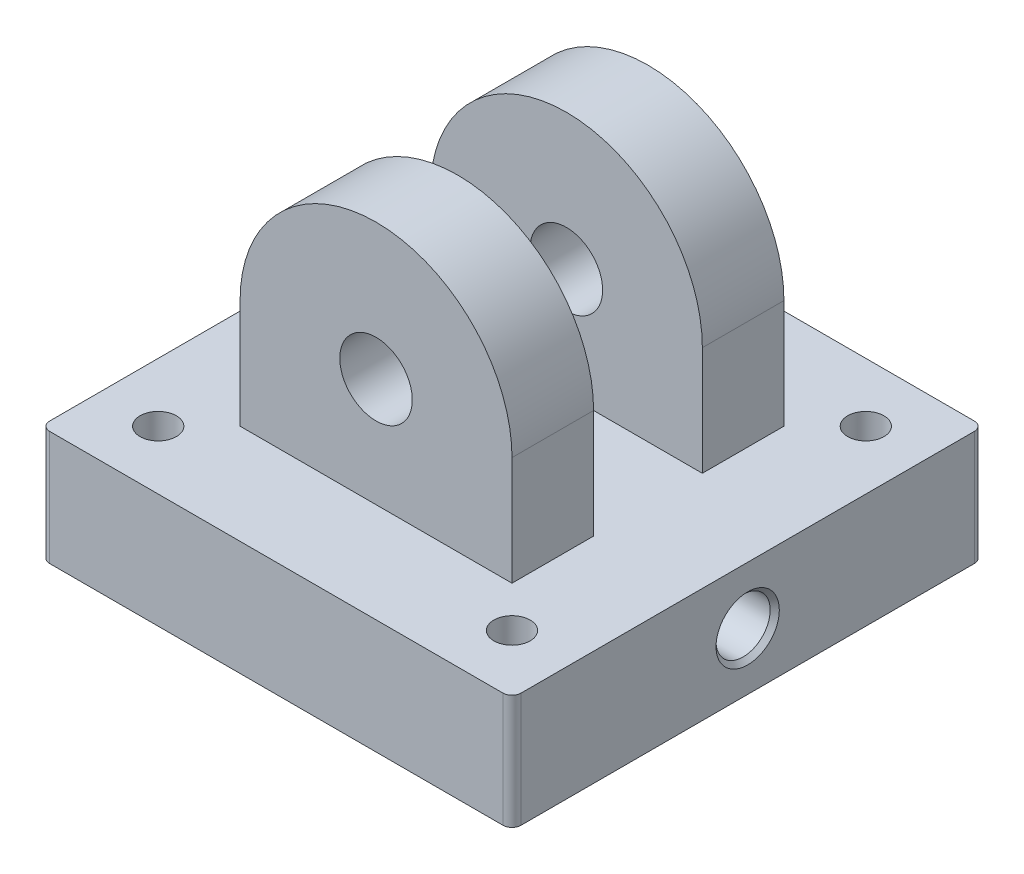
from build123d import *

# Parameters (mm, degrees)
SKETCH1_W                              = 165.1
SKETCH1_H                              = 165.1
BOSS_EXTRUDE1_DEPTH                    = 38.1
BOSS_EXTRUDE1_DEPTH_BACK               = 2
SKETCH2_W                              = 95.25
SKETCH2_H                              = 95.25
BOSS_EXTRUDE2_DEPTH                    = 38.1
BOSS_EXTRUDE3_START                    = -95.25
BOSS_EXTRUDE3_DEPTH                    = 95.25
SKETCH7_R                              = 12.7
CUT_EXTRUDE1_DEPTH                     = 131.175
SKETCH8_W                              = 38.1
SKETCH8_H                              = 1000
CUT_EXTRUDE2_DEPTH                     = 131.175
FILLET1_R                              = 3.175
SKETCH9_R                              = 26
CUT_EXTRUDE3_DEPTH                     = 36.83
SKETCH10_R                             = 76.2
SKETCH10_R_2                           = 69.85
CUT_EXTRUDE4_DEPTH                     = 8
F_1_2_14_NPSM_TAPPED_HOLE2_D           = 18.9738
F_1_2_14_NPSM_TAPPED_HOLE2_DEPTH       = 63.5
F_1_2_14_NPSM_TAPPED_HOLE2_CSINK_D     = 22.1742
F_1_2_14_NPSM_TAPPED_HOLE2_CSINK_ANGLE = 90
F_1_2_14_NPSM_TAPPED_HOLE2_TIP         = 5.700304607
SKETCH16_R                             = 6.35
CUT_EXTRUDE5_DEPTH                     = 25
SKETCH17_R                             = 6.35
CUT_EXTRUDE6_DEPTH                     = 126.825


with BuildPart() as part:
    # Sketch1 → Boss-Extrude1 (new body, two sides)
    with BuildSketch(Plane(origin=(0, 0, 0), x_dir=(1, 0, 0), z_dir=(0, 1, 0))) as boss_extrude1_sk:
        Rectangle(SKETCH1_W, SKETCH1_H)
    extrude(amount=BOSS_EXTRUDE1_DEPTH)
    extrude(boss_extrude1_sk.sketch, amount=-BOSS_EXTRUDE1_DEPTH_BACK)

    # Sketch2 → Boss-Extrude2 (add)
    with BuildSketch(Plane(origin=(0, 38.1, 0), x_dir=(1, 0, 0), z_dir=(0, 1, 0))):
        Rectangle(SKETCH2_W, SKETCH2_H)
    extrude(amount=BOSS_EXTRUDE2_DEPTH)

    # Sketch3 → Boss-Extrude3 (add)
    with BuildSketch(Plane(origin=(0, 0, -47.625), x_dir=(-1, 0, 0), z_dir=(0, 0, -1)).offset(BOSS_EXTRUDE3_START)):
        with BuildLine():
            Line((47.625, 76.2), (-47.625, 76.2))
            ThreePointArc((-47.625, 76.2), (0, 123.825), (47.625, 76.2))
        make_face()
    extrude(amount=BOSS_EXTRUDE3_DEPTH)

    # Sketch7 → Cut-Extrude1 (cut, through all)
    with BuildSketch(Plane(origin=(0, 0, -47.625), x_dir=(-1, 0, 0), z_dir=(0, 0, -1))):
        with Locations((0, 76.2)):
            Circle(SKETCH7_R)
    extrude(amount=-CUT_EXTRUDE1_DEPTH, mode=Mode.SUBTRACT)

    # Sketch8 → Cut-Extrude2 (cut, through all)
    with BuildSketch(Plane(origin=(47.625, 0, 0), x_dir=(0, 0, -1), z_dir=(1, 0, 0))):
        with Locations((0, 538.1)):
            Rectangle(SKETCH8_W, SKETCH8_H)
    extrude(amount=-CUT_EXTRUDE2_DEPTH, mode=Mode.SUBTRACT)

    # Fillet1
    fillet1_edges = [part.edges().sort_by_distance(p)[0] for p in [
        (82.55, 18.05, 82.55),
        (-82.55, 18.05, 82.55),
        (-82.55, 18.05, -82.55),
        (82.55, 18.05, -82.55),
    ]]
    fillet(fillet1_edges, radius=FILLET1_R)

    # Sketch9 → Cut-Extrude3 (cut)
    with BuildSketch(Plane.XZ.offset(2)):
        Circle(SKETCH9_R)
    extrude(amount=-CUT_EXTRUDE3_DEPTH, mode=Mode.SUBTRACT)

    # Sketch10 → Cut-Extrude4 (cut)
    with BuildSketch(Plane.XZ.offset(2)):
        Circle(SKETCH10_R)
        Circle(SKETCH10_R_2, mode=Mode.SUBTRACT)
    extrude(amount=-CUT_EXTRUDE4_DEPTH, mode=Mode.SUBTRACT)

    # 1/2-14 NPSM Tapped Hole2
    with Locations(Plane(origin=(82.55, 0, 0), x_dir=(0, 0, -1), z_dir=(1, 0, 0))):
        with Locations((0, 18.05)):
            CounterSinkHole(F_1_2_14_NPSM_TAPPED_HOLE2_D / 2, F_1_2_14_NPSM_TAPPED_HOLE2_CSINK_D / 2, depth=F_1_2_14_NPSM_TAPPED_HOLE2_DEPTH, counter_sink_angle=F_1_2_14_NPSM_TAPPED_HOLE2_CSINK_ANGLE)
            with Locations((0, 0, -(F_1_2_14_NPSM_TAPPED_HOLE2_DEPTH + F_1_2_14_NPSM_TAPPED_HOLE2_TIP / 2))):  # 118° drill point
                Cone(0, F_1_2_14_NPSM_TAPPED_HOLE2_D / 2, F_1_2_14_NPSM_TAPPED_HOLE2_TIP, mode=Mode.SUBTRACT)

    # Sketch16 → Cut-Extrude5 (cut)
    with BuildSketch(Plane.XZ.offset(2)):
        with Locations((50.55, 0)):
            Circle(SKETCH16_R)
    extrude(amount=-CUT_EXTRUDE5_DEPTH, mode=Mode.SUBTRACT)

    # Sketch17 → Cut-Extrude6 (cut, through all)
    with BuildSketch(Plane.XZ.offset(2)):
        with Locations((-61.963767235, 61.963767235)):
            Circle(SKETCH17_R)
        with Locations((61.963767235, 61.963767235)):
            Circle(SKETCH17_R)
        with Locations((61.963767235, -61.963767235)):
            Circle(SKETCH17_R)
        with Locations((-61.963767235, -61.963767235)):
            Circle(SKETCH17_R)
    extrude(amount=-CUT_EXTRUDE6_DEPTH, mode=Mode.SUBTRACT)


solid = part.part
